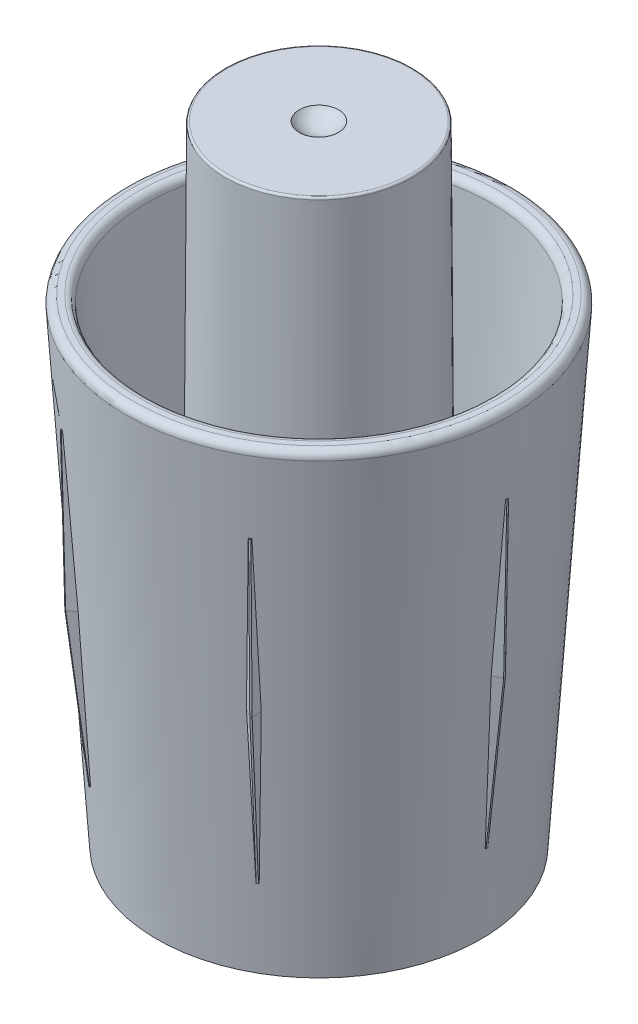
from build123d import *

# Parameters (mm, degrees)
CIRPATTERN1_COUNT  = 6
SKETCH6_R          = 6.79
CUT_EXTRUDE3_DEPTH = 5
CIRPATTERN2_COUNT  = 3
FILLET1_R          = 0.1
FILLET2_R          = 0.36


with BuildPart() as part:
    # Sketch1 → Revolve1 (revolve)
    with BuildSketch(Plane.XY):
        Polygon((0, 0), (7.79, 0), (9.3, 22.95), (8.3, 22.95), (7.345916913, 8.449200771), (4.6, 13.16), (4.5, 30.16), (0, 30.16), (0, 29.16), (3.5, 29.16), (3.594117647, 13.16), (7.184771242, 7), (6.79, 1), (0, 1), align=None)
    revolve(axis=Axis((0, 30.16, 0), (0, -1, 0)))

    # Sweep1: sweep along a path in Sketch3
    with BuildLine(Plane.XY) as sweep1_path:
        Line((8.810371341, 18.97), (8.65516836, 11.47))
        Line((8.65516836, 11.47), (7.811420259, 3.97))
    # Sketch4 → Sweep1 (sweep)
    with BuildSketch(Plane(origin=(8.810371341, 18.97, 0), x_dir=(-0.999785953, 0.020689301, 0), z_dir=(-0.020689301, -0.999785953, 0))):
        with BuildLine():
            Line((-0.26603221, -0.041255211), (0.171094577, -0.29363048))
            Line((0.171094577, -0.29363048), (0.171094577, 0.29363048))
            Line((0.171094577, 0.29363048), (-0.26603221, 0.041255211))
            ThreePointArc((-0.26603221, 0.041255211), (-0.283120678, 0), (-0.26603221, -0.041255211))
        make_face()
    sweep1 = sweep(path=sweep1_path.line, transition=Transition.RIGHT)

    # CirPattern1: Sweep1 ×6 about axis
    cirpattern1_axis = Axis((0, 0, 0), (0, 1, 0))
    for i in range(1, CIRPATTERN1_COUNT):
        add(sweep1.rotate(cirpattern1_axis, i * 360 / CIRPATTERN1_COUNT))

    # Sketch6 → Cut-Extrude3 (cut)
    with BuildSketch(Plane(origin=(0, 0, 0), x_dir=(-1, 0, 0), z_dir=(0, -1, 0))):
        Circle(SKETCH6_R)
    extrude(amount=-CUT_EXTRUDE3_DEPTH, mode=Mode.SUBTRACT)

    # Sketch8 → Cut-Revolve1 (revolve, cut)
    with BuildSketch(Plane.XY):
        with BuildLine():
            Line((0, 30.16), (0, 29.71))
            ThreePointArc((0, 29.71), (0.523336651, 29.828243033), (0.945, 30.16))
            Line((0.945, 30.16), (0, 30.16))
        make_face()
    revolve(axis=Axis((0, 30.16, 0), (0, -1, 0)), mode=Mode.SUBTRACT)

    # Cut-Sweep1: sweep along a path in Sketch10
    with BuildLine(Plane(origin=(0, 0, 0), x_dir=(0, 0, -1), z_dir=(1, 0, 0))) as cut_sweep1_path:
        Line((7.136016143, 13.16), (6.444278912, -0.050096922))
    # Sketch9 → Cut-Sweep1 (sweep, cut)
    with BuildSketch(Plane(origin=(0, 13.16, 0), x_dir=(1, 0, 0), z_dir=(0, 1, 0))):
        with BuildLine():
            ThreePointArc((3.161458886, 7.11964028), (1.867795779, 7.562766619), (0.516578249, 7.772853203))
            ThreePointArc((0.516578249, 7.772853203), (0.250550282, 7.539981734), (0.483421751, 7.273953767))
            ThreePointArc((0.483421751, 7.273953767), (1.747911583, 7.07735156), (2.958541114, 6.662667219))
            ThreePointArc((2.958541114, 6.662667219), (3.28848653, 6.789694864), (3.161458886, 7.11964028))
        make_face()
        with BuildLine():
            ThreePointArc((-0.483421751, 7.273953767), (-1.747911583, 7.07735156), (-2.958541114, 6.662667219))
            ThreePointArc((-2.958541114, 6.662667219), (-3.28848653, 6.789694864), (-3.161458886, 7.11964028))
            ThreePointArc((-3.161458886, 7.11964028), (-1.867795779, 7.562766619), (-0.516578249, 7.772853203))
            ThreePointArc((-0.516578249, 7.772853203), (-0.250550282, 7.539981734), (-0.483421751, 7.273953767))
        make_face()
    cut_sweep1 = sweep(path=cut_sweep1_path.line, mode=Mode.SUBTRACT)

    # CirPattern2: Cut-Sweep1 ×3 about axis
    cirpattern2_axis = Axis((0, 30.16, 0), (0, 1, 0))
    for i in range(1, CIRPATTERN2_COUNT):
        add(cut_sweep1.rotate(cirpattern2_axis, i * 360 / CIRPATTERN2_COUNT), mode=Mode.SUBTRACT)

    # Fillet1
    fillet1_edges = [part.edges().sort_by_distance(p)[0] for p in [
        (-4.5, 30.16, 0),
    ]]
    fillet(fillet1_edges, radius=FILLET1_R)

    # Fillet2
    fillet2_edges = [part.edges().sort_by_distance(p)[0] for p in [
        (-8.3, 22.95, 0),
        (-9.3, 22.95, 0),
    ]]
    fillet(fillet2_edges, radius=FILLET2_R)

    # Sketch11 → Cut-Revolve2 (revolve, cut)
    with BuildSketch(Plane.XY):
        Polygon((7.565766612, 0), (6.803900832, 3.135056842), (4.411866106, 0), align=None)
    revolve(axis=Axis((0, 0, 0), (0, 1, 0)), mode=Mode.SUBTRACT)


solid = part.part
